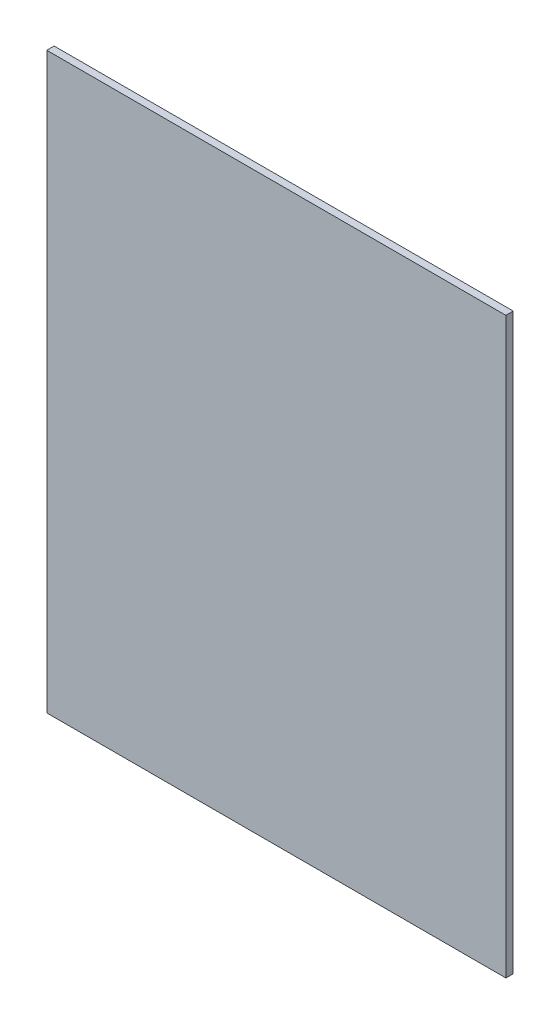
from build123d import *

# Parameters (mm, degrees)
SKETCH1_W           = 198.12
SKETCH1_H           = 247.65
BOSS_EXTRUDE1_DEPTH = 3.175


with BuildPart() as part:
    # Sketch1 → Boss-Extrude1 (new body)
    with BuildSketch(Plane.XY):
        Rectangle(SKETCH1_W, SKETCH1_H)
    extrude(amount=BOSS_EXTRUDE1_DEPTH)


solid = part.part
